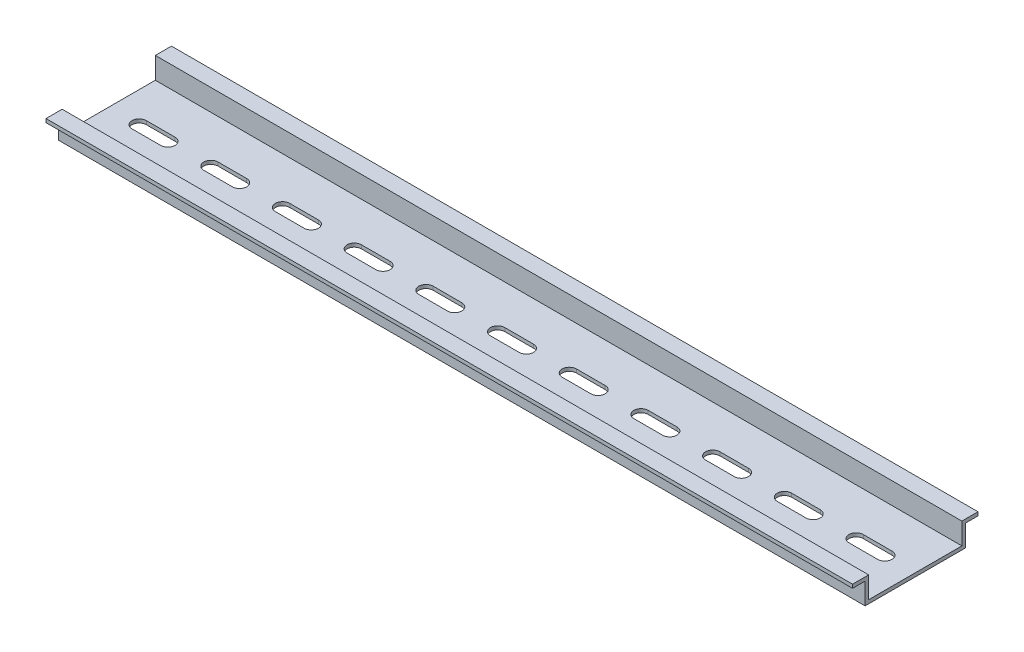
from build123d import *

# Parameters (mm, degrees)
SKETCH1_W           = 225
SKETCH1_H           = 35
BOSS_EXTRUDE1_DEPTH = 3.5
SKETCH2_W           = 3.5
SKETCH2_H           = 6
CUT_EXTRUDE1_DEPTH  = 226
CUT_EXTRUDE2_DEPTH  = 2


with BuildPart() as part:
    # Sketch1 → Boss-Extrude1 (new body, symmetric)
    with BuildSketch(Plane(origin=(0, 0, 0), x_dir=(1, 0, 0), z_dir=(0, 1, 0))):
        Rectangle(SKETCH1_W, SKETCH1_H)
    extrude(amount=BOSS_EXTRUDE1_DEPTH, both=True)

    # Sketch2 → Cut-Extrude1 (cut, through all)
    with BuildSketch(Plane(origin=(112.5, 0, 0), x_dir=(0, 0, -1), z_dir=(1, 0, 0))):
        Polygon((-13, -2.5), (0, -2.5), (13, -2.5), (13, 3.5), (-13, 3.5), align=None)
        with Locations((15.75, -0.5)):
            Rectangle(SKETCH2_W, SKETCH2_H)
        with Locations((-15.75, -0.5)):
            Rectangle(SKETCH2_W, SKETCH2_H)
    extrude(amount=-CUT_EXTRUDE1_DEPTH, mode=Mode.SUBTRACT)

    # Sketch3 → Cut-Extrude2 (cut, through all)
    with BuildSketch(Plane(origin=(0, -2.5, 0), x_dir=(1, 0, 0), z_dir=(0, 1, 0))):
        with BuildLine():
            Line((-4, 2), (4, 2))
            ThreePointArc((4, 2), (6, 0), (4, -2))
            Line((4, -2), (-4, -2))
            ThreePointArc((-4, -2), (-6, 0), (-4, 2))
        make_face()
        with BuildLine():
            Line((16, 2), (24, 2))
            ThreePointArc((24, 2), (26, 0), (24, -2))
            Line((24, -2), (16, -2))
            ThreePointArc((16, -2), (14, 0), (16, 2))
        make_face()
        with BuildLine():
            Line((36, 2), (44, 2))
            ThreePointArc((44, 2), (46, 0), (44, -2))
            Line((44, -2), (36, -2))
            ThreePointArc((36, -2), (34, 0), (36, 2))
        make_face()
        with BuildLine():
            Line((56, 2), (64, 2))
            ThreePointArc((64, 2), (66, 0), (64, -2))
            Line((64, -2), (56, -2))
            ThreePointArc((56, -2), (54, 0), (56, 2))
        make_face()
        with BuildLine():
            Line((76, 2), (84, 2))
            ThreePointArc((84, 2), (86, 0), (84, -2))
            Line((84, -2), (76, -2))
            ThreePointArc((76, -2), (74, 0), (76, 2))
        make_face()
        with BuildLine():
            Line((-24, 2), (-16, 2))
            ThreePointArc((-16, 2), (-14, 0), (-16, -2))
            Line((-16, -2), (-24, -2))
            ThreePointArc((-24, -2), (-26, 0), (-24, 2))
        make_face()
        with BuildLine():
            Line((-44, 2), (-36, 2))
            ThreePointArc((-36, 2), (-34, 0), (-36, -2))
            Line((-36, -2), (-44, -2))
            ThreePointArc((-44, -2), (-46, 0), (-44, 2))
        make_face()
        with BuildLine():
            Line((-64, 2), (-56, 2))
            ThreePointArc((-56, 2), (-54, 0), (-56, -2))
            Line((-56, -2), (-64, -2))
            ThreePointArc((-64, -2), (-66, 0), (-64, 2))
        make_face()
        with BuildLine():
            Line((-84, 2), (-76, 2))
            ThreePointArc((-76, 2), (-74, 0), (-76, -2))
            Line((-76, -2), (-84, -2))
            ThreePointArc((-84, -2), (-86, 0), (-84, 2))
        make_face()
        with BuildLine():
            Line((-104, 2), (-96, 2))
            ThreePointArc((-96, 2), (-94, 0), (-96, -2))
            Line((-96, -2), (-104, -2))
            ThreePointArc((-104, -2), (-106, 0), (-104, 2))
        make_face()
        with BuildLine():
            Line((-124, 2), (-116, 2))
            ThreePointArc((-116, 2), (-114, 0), (-116, -2))
            Line((-116, -2), (-124, -2))
            ThreePointArc((-124, -2), (-126, 0), (-124, 2))
        make_face()
        with BuildLine():
            Line((-144, 2), (-136, 2))
            ThreePointArc((-136, 2), (-134, 0), (-136, -2))
            Line((-136, -2), (-144, -2))
            ThreePointArc((-144, -2), (-146, 0), (-144, 2))
        make_face()
        with BuildLine():
            Line((96, 2), (104, 2))
            ThreePointArc((104, 2), (106, 0), (104, -2))
            Line((104, -2), (96, -2))
            ThreePointArc((96, -2), (94, 0), (96, 2))
        make_face()
        with BuildLine():
            Line((116, 2), (124, 2))
            ThreePointArc((124, 2), (126, 0), (124, -2))
            Line((124, -2), (116, -2))
            ThreePointArc((116, -2), (114, 0), (116, 2))
        make_face()
        with BuildLine():
            Line((136, 2), (144, 2))
            ThreePointArc((144, 2), (146, 0), (144, -2))
            Line((144, -2), (136, -2))
            ThreePointArc((136, -2), (134, 0), (136, 2))
        make_face()
    extrude(amount=-CUT_EXTRUDE2_DEPTH, mode=Mode.SUBTRACT)


solid = part.part
